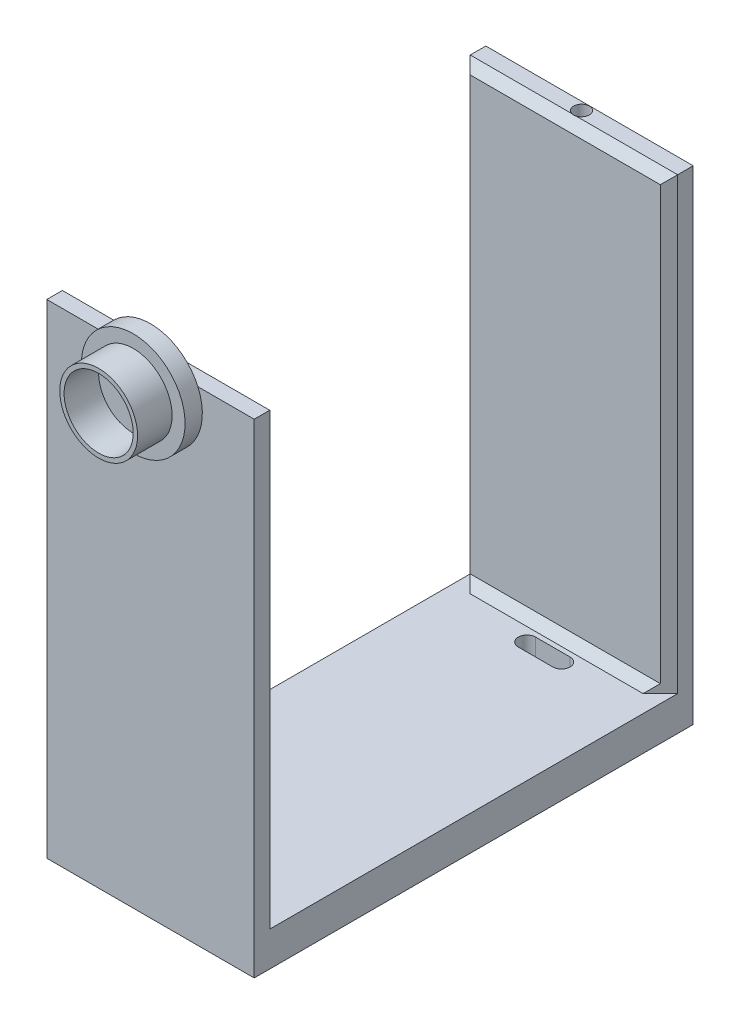
from build123d import *

# Parameters (mm, degrees)
SKETCH1_W           = 12
SKETCH1_H           = 12.7
BOSS_EXTRUDE1_DEPTH = 2
SKETCH2_W           = 12
SKETCH2_H           = 1.4
BOSS_EXTRUDE2_DEPTH = 26
CHAMFER1_SIZE       = 0.5
CHAMFER2_SIZE       = 0.5
SKETCH3_R           = 0.45
CUT_EXTRUDE1_DEPTH  = 5
CUT_EXTRUDE2_DEPTH  = 5
SKETCH5_R           = 3
BOSS_EXTRUDE3_DEPTH = 1
SKETCH6_R           = 2.25
BOSS_EXTRUDE4_DEPTH = 2
SKETCH7_R           = 2
CUT_EXTRUDE3_DEPTH  = 2


with BuildPart() as part:
    # Sketch1 → Boss-Extrude1 (new body)
    with BuildSketch(Plane(origin=(0, 0, 0), x_dir=(1, 0, 0), z_dir=(0, 1, 0))):
        with Locations((0, -6.35)):
            Rectangle(SKETCH1_W, SKETCH1_H)
    boss_extrude1 = extrude(amount=-BOSS_EXTRUDE1_DEPTH)

    # Sketch2 → Boss-Extrude2 (add)
    with BuildSketch(Plane(origin=(0, 0, 0), x_dir=(1, 0, 0), z_dir=(0, 1, 0))):
        with Locations((0, -12)):
            Rectangle(SKETCH2_W, SKETCH2_H)
    boss_extrude2 = extrude(amount=BOSS_EXTRUDE2_DEPTH)

    # Mirror1: Boss-Extrude1, Boss-Extrude2 across plane
    add(boss_extrude1.mirror(Plane.XY))
    add(boss_extrude2.mirror(Plane.XY))

    # Chamfer1
    chamfer1_edges = [part.edges().sort_by_distance(p)[0] for p in [
        (-6, 13, 11.3),
        (6, 13, 11.3),
        (0, 26, 11.3),
        (0, 26, -11.3),
        (-6, 13, -11.3),
        (6, 13, -11.3),
    ]]
    chamfer(chamfer1_edges, length=CHAMFER1_SIZE)

    # Chamfer2
    chamfer2_edges = [part.edges().sort_by_distance(p)[0] for p in [
        (0, 0, -11.3),
        (0, 0, 11.3),
    ]]
    chamfer(chamfer2_edges, length=CHAMFER2_SIZE)

    # Sketch3 → Cut-Extrude1 (cut)
    with BuildSketch(Plane(origin=(0, 26, 0), x_dir=(1, 0, 0), z_dir=(0, 1, 0))):
        with Locations((0, -12.237441552)):
            Circle(SKETCH3_R)
        with Locations((0, 12.237441552)):
            Circle(SKETCH3_R)
    extrude(amount=-CUT_EXTRUDE1_DEPTH, mode=Mode.SUBTRACT)

    # Sketch4 → Cut-Extrude2 (cut)
    with BuildSketch(Plane(origin=(0, 0, 0), x_dir=(1, 0, 0), z_dir=(0, 1, 0))):
        with BuildLine():
            Line((-0.944927116, 10.523894152), (1.056095012, 10.523894152))
            ThreePointArc((1.056095012, 10.523894152), (1.556095012, 10.023894152), (1.056095012, 9.523894152))
            Line((1.056095012, 9.523894152), (-0.944927116, 9.523894152))
            ThreePointArc((-0.944927116, 9.523894152), (-1.444927116, 10.023894152), (-0.944927116, 10.523894152))
        make_face()
        with BuildLine():
            Line((-0.944927116, -10.523894152), (1.056095012, -10.523894152))
            ThreePointArc((1.056095012, -10.523894152), (1.556095012, -10.023894152), (1.056095012, -9.523894152))
            Line((1.056095012, -9.523894152), (-0.944927116, -9.523894152))
            ThreePointArc((-0.944927116, -9.523894152), (-1.444927116, -10.023894152), (-0.944927116, -10.523894152))
        make_face()
    extrude(amount=-CUT_EXTRUDE2_DEPTH, mode=Mode.SUBTRACT)

    # Sketch5 → Boss-Extrude3 (add)
    with BuildSketch(Plane.XY.offset(12.7)):
        with Locations((0, 24.785766933)):
            Circle(SKETCH5_R)
    extrude(amount=BOSS_EXTRUDE3_DEPTH)

    # Sketch6 → Boss-Extrude4 (add)
    with BuildSketch(Plane.XY.offset(13.7)):
        with Locations((0, 24.799373819)):
            Circle(SKETCH6_R)
    extrude(amount=BOSS_EXTRUDE4_DEPTH)

    # Sketch7 → Cut-Extrude3 (cut)
    with BuildSketch(Plane.XY.offset(15.7)):
        with Locations((0, 24.799373819)):
            Circle(SKETCH7_R)
    extrude(amount=-CUT_EXTRUDE3_DEPTH, mode=Mode.SUBTRACT)


solid = part.part
